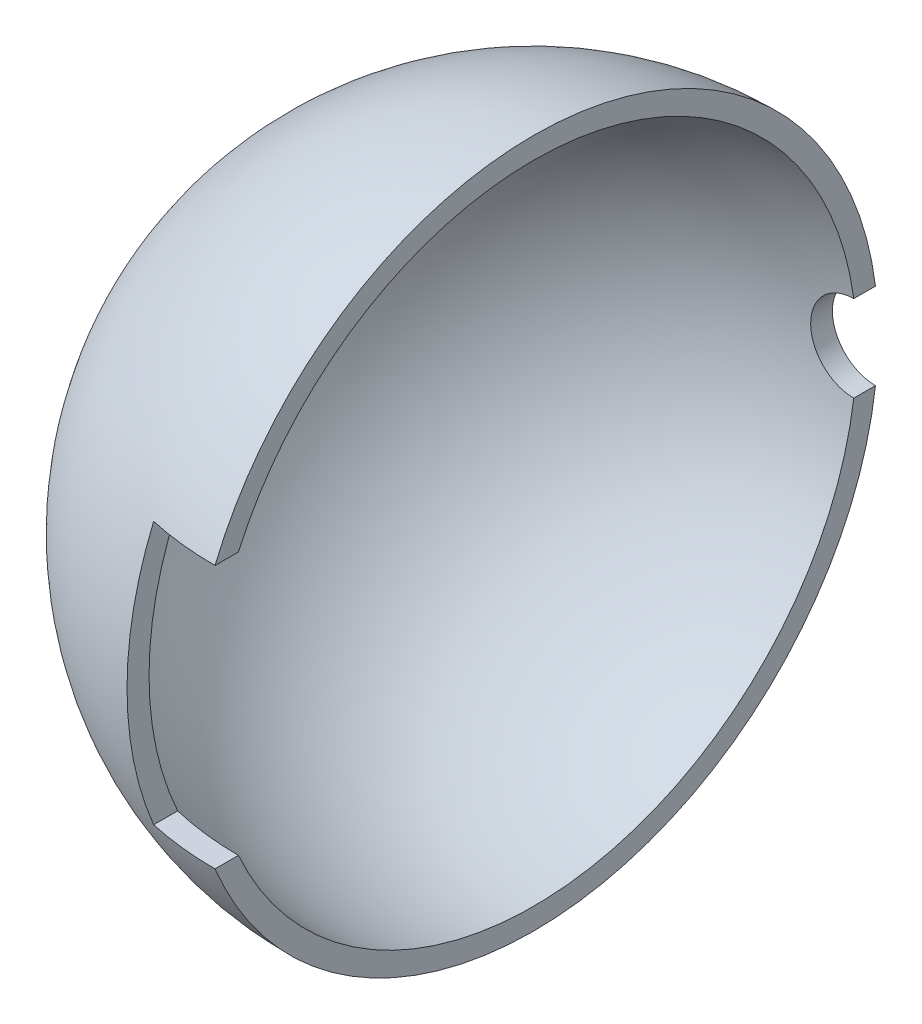
from build123d import *

# Parameters (mm, degrees)
SKETCH2_W          = 3.2
SKETCH2_H          = 6.1
CUT_EXTRUDE1_DEPTH = 2
CUT_EXTRUDE2_REACH = 17.838
SKETCH3_R          = 1


with BuildPart() as part:
    # Sketch1 → Revolve1 (revolve)
    with BuildSketch(Plane.XY):
        with BuildLine():
            Line((0, 8), (0, 7.5))
            ThreePointArc((0, 7.5), (-5.303300859, 5.303300859), (-7.5, 0))
            Line((-7.5, 0), (-8, 0))
            ThreePointArc((-8, 0), (-5.656854249, 5.656854249), (0, 8))
        make_face()
    revolve(axis=Axis((-8, 0, 0), (1, 0, 0)))

    # Sketch2 → Cut-Extrude1 (cut)
    with BuildSketch(Plane.XY.offset(8)):
        Rectangle(SKETCH2_W, SKETCH2_H)
    extrude(amount=-CUT_EXTRUDE1_DEPTH, mode=Mode.SUBTRACT)

    # Sketch3 → Cut-Extrude2 (cut, up to next)
    with BuildSketch(Plane.XY.offset(-8), mode=Mode.PRIVATE) as cut_extrude2_sk1:
        Circle(SKETCH3_R)
    cut_extrude2_tool1 = extrude(cut_extrude2_sk1.sketch, amount=CUT_EXTRUDE2_REACH, mode=Mode.PRIVATE) & part.part
    add(cut_extrude2_tool1.solids().sort_by_distance((0, 0, -8))[0], mode=Mode.SUBTRACT)


solid = part.part
